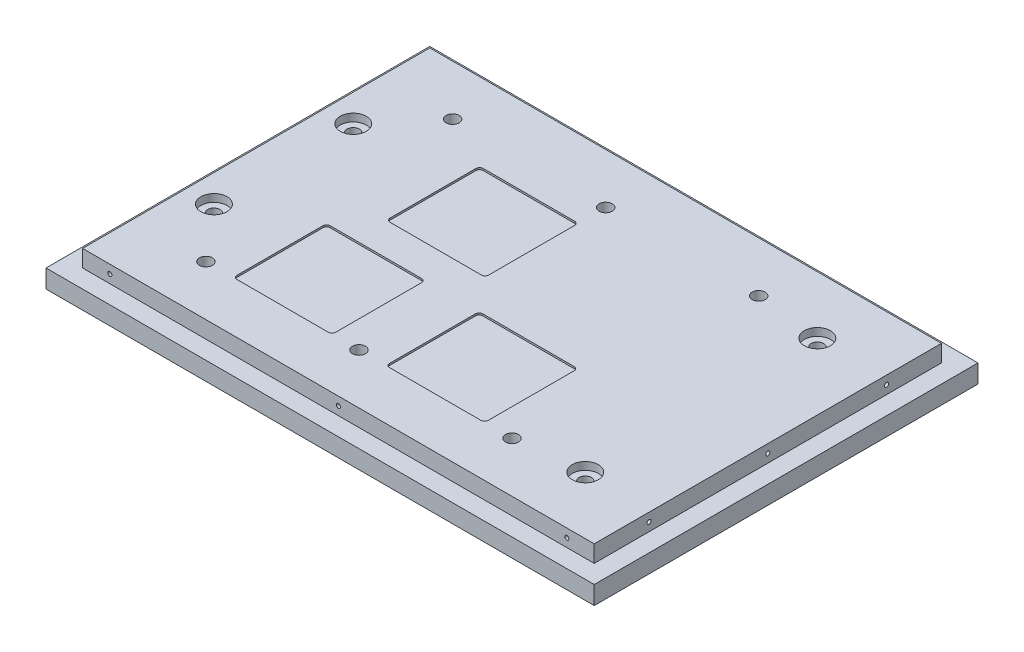
from build123d import *

# Parameters (mm, degrees)
SKETCH1_W                                            = 300
SKETCH1_H                                            = 210
BOSS_EXTRUDE1_DEPTH                                  = 10
SKETCH2_W                                            = 280
SKETCH2_H                                            = 190
BOSS_EXTRUDE2_DEPTH                                  = 9.28
F_1_4_20_CLEARANCE_HOLES_REACH                       = 21.28
SKETCH3_R                                            = 3.57
SKETCH4_R                                            = 7.5
CUT_EXTRUDE2_DEPTH                                   = 10
SKETCH11_W                                           = 54
SKETCH11_H                                           = 51
TEC_DEPTH                                            = 1
FILLET1_R                                            = 2
F_4_40_TAPPED_HOLE1_D                                = 2.2606
F_4_40_TAPPED_HOLE1_DEPTH                            = 13
F_4_40_TAPPED_HOLE1_TIP                              = 0.679152758
F_4_40_TAPPED_HOLE2_D                                = 2.2606
F_4_40_TAPPED_HOLE2_DEPTH                            = 13
F_4_40_TAPPED_HOLE2_TIP                              = 0.679152758
F_4_40_TAPPED_HOLE3_D                                = 2.2606
F_4_40_TAPPED_HOLE3_DEPTH                            = 13
F_4_40_TAPPED_HOLE3_TIP                              = 0.679152758
F_4_40_TAPPED_HOLE4_D                                = 2.2606
F_4_40_TAPPED_HOLE4_DEPTH                            = 13
F_4_40_TAPPED_HOLE4_TIP                              = 0.679152758
CBORE_FOR_1_4_BINDING_HEAD_MACHINE_SCREW_D           = 6.7564
CBORE_FOR_1_4_BINDING_HEAD_MACHINE_SCREW_CBORE_D     = 14.2875
CBORE_FOR_1_4_BINDING_HEAD_MACHINE_SCREW_CBORE_DEPTH = 4.191


with BuildPart() as part:
    # Sketch1 → Boss-Extrude1 (new body)
    with BuildSketch(Plane(origin=(0, 0, 0), x_dir=(1, 0, 0), z_dir=(0, 1, 0))):
        with Locations((-22.864321608, -2.487437186)):
            Rectangle(SKETCH1_W, SKETCH1_H)
    extrude(amount=BOSS_EXTRUDE1_DEPTH)

    # Sketch2 → Boss-Extrude2 (add)
    with BuildSketch(Plane(origin=(0, 10, 0), x_dir=(1, 0, 0), z_dir=(0, 1, 0))):
        with Locations((-22.864321608, -2.487437186)):
            Rectangle(SKETCH2_W, SKETCH2_H)
    extrude(amount=BOSS_EXTRUDE2_DEPTH)

    # Sketch3 → 1/4-20 clearance holes (cut, up to next)
    with BuildSketch(Plane(origin=(0, 19.28, 0), x_dir=(1, 0, 0), z_dir=(0, 1, 0)), mode=Mode.PRIVATE) as f_1_4_20_clearance_holes_sk1:
        with Locations((-122.864321608, 65.012562814)):
            Circle(SKETCH3_R)
    f_1_4_20_clearance_holes_tool1 = extrude(f_1_4_20_clearance_holes_sk1.sketch, amount=-F_1_4_20_CLEARANCE_HOLES_REACH, mode=Mode.PRIVATE) & part.part
    add(f_1_4_20_clearance_holes_tool1.solids().sort_by_distance((-122.864322, 19.28, -65.012563))[0], mode=Mode.SUBTRACT)
    # Sketch3 → 1/4-20 clearance holes (cut, up to next)
    with BuildSketch(Plane(origin=(0, 19.28, 0), x_dir=(1, 0, 0), z_dir=(0, 1, 0)), mode=Mode.PRIVATE) as f_1_4_20_clearance_holes_sk2:
        with Locations((-39.114321608, 65.012562814)):
            Circle(SKETCH3_R)
    f_1_4_20_clearance_holes_tool2 = extrude(f_1_4_20_clearance_holes_sk2.sketch, amount=-F_1_4_20_CLEARANCE_HOLES_REACH, mode=Mode.PRIVATE) & part.part
    add(f_1_4_20_clearance_holes_tool2.solids().sort_by_distance((-39.114322, 19.28, -65.012563))[0], mode=Mode.SUBTRACT)
    # Sketch3 → 1/4-20 clearance holes (cut, up to next)
    with BuildSketch(Plane(origin=(0, 19.28, 0), x_dir=(1, 0, 0), z_dir=(0, 1, 0)), mode=Mode.PRIVATE) as f_1_4_20_clearance_holes_sk3:
        with Locations((44.635678392, 65.012562814)):
            Circle(SKETCH3_R)
    f_1_4_20_clearance_holes_tool3 = extrude(f_1_4_20_clearance_holes_sk3.sketch, amount=-F_1_4_20_CLEARANCE_HOLES_REACH, mode=Mode.PRIVATE) & part.part
    add(f_1_4_20_clearance_holes_tool3.solids().sort_by_distance((44.635678, 19.28, -65.012563))[0], mode=Mode.SUBTRACT)
    # Sketch3 → 1/4-20 clearance holes (cut, up to next)
    with BuildSketch(Plane(origin=(0, 19.28, 0), x_dir=(1, 0, 0), z_dir=(0, 1, 0)), mode=Mode.PRIVATE) as f_1_4_20_clearance_holes_sk4:
        with Locations((44.635678392, -69.987437186)):
            Circle(SKETCH3_R)
    f_1_4_20_clearance_holes_tool4 = extrude(f_1_4_20_clearance_holes_sk4.sketch, amount=-F_1_4_20_CLEARANCE_HOLES_REACH, mode=Mode.PRIVATE) & part.part
    add(f_1_4_20_clearance_holes_tool4.solids().sort_by_distance((44.635678, 19.28, 69.987437))[0], mode=Mode.SUBTRACT)
    # Sketch3 → 1/4-20 clearance holes (cut, up to next)
    with BuildSketch(Plane(origin=(0, 19.28, 0), x_dir=(1, 0, 0), z_dir=(0, 1, 0)), mode=Mode.PRIVATE) as f_1_4_20_clearance_holes_sk5:
        with Locations((-39.114321608, -69.987437186)):
            Circle(SKETCH3_R)
    f_1_4_20_clearance_holes_tool5 = extrude(f_1_4_20_clearance_holes_sk5.sketch, amount=-F_1_4_20_CLEARANCE_HOLES_REACH, mode=Mode.PRIVATE) & part.part
    add(f_1_4_20_clearance_holes_tool5.solids().sort_by_distance((-39.114322, 19.28, 69.987437))[0], mode=Mode.SUBTRACT)
    # Sketch3 → 1/4-20 clearance holes (cut, up to next)
    with BuildSketch(Plane(origin=(0, 19.28, 0), x_dir=(1, 0, 0), z_dir=(0, 1, 0)), mode=Mode.PRIVATE) as f_1_4_20_clearance_holes_sk6:
        with Locations((-122.864321608, -69.987437186)):
            Circle(SKETCH3_R)
    f_1_4_20_clearance_holes_tool6 = extrude(f_1_4_20_clearance_holes_sk6.sketch, amount=-F_1_4_20_CLEARANCE_HOLES_REACH, mode=Mode.PRIVATE) & part.part
    add(f_1_4_20_clearance_holes_tool6.solids().sort_by_distance((-122.864322, 19.28, 69.987437))[0], mode=Mode.SUBTRACT)

    # Sketch4 → Cut-Extrude2 (cut)
    with BuildSketch(Plane.XZ):
        with Locations((-122.864321608, 69.987437186)):
            Circle(SKETCH4_R)
        with Locations((-39.114321608, 69.987437186)):
            Circle(SKETCH4_R)
        with Locations((44.635678392, 69.987437186)):
            Circle(SKETCH4_R)
        with Locations((44.635678392, -65.012562814)):
            Circle(SKETCH4_R)
        with Locations((-39.114321608, -65.012562814)):
            Circle(SKETCH4_R)
        with Locations((-122.864321608, -65.012562814)):
            Circle(SKETCH4_R)
    extrude(amount=-CUT_EXTRUDE2_DEPTH, mode=Mode.SUBTRACT)

    # Sketch11 → TEC (cut)
    with BuildSketch(Plane(origin=(0, 19.28, 0), x_dir=(1, 0, 0), z_dir=(0, 1, 0))):
        with Locations((-66.114321608, 24.512562814)):
            Rectangle(SKETCH11_W, SKETCH11_H)
        with Locations((-80.864321608, -44.487437186)):
            Rectangle(SKETCH11_W, SKETCH11_H)
        with Locations((2.635678392, -44.487437186)):
            Rectangle(SKETCH11_W, SKETCH11_H)
    extrude(amount=-TEC_DEPTH, mode=Mode.SUBTRACT)

    # Fillet1
    fillet1_edges = [part.edges().sort_by_distance(p)[0] for p in [
        (29.635678392, 18.78, 69.987437186),
        (-24.364321608, 18.78, 69.987437186),
        (-24.364321608, 18.78, 18.987437186),
        (29.635678392, 18.78, 18.987437186),
        (-39.114321608, 18.78, -50.012562814),
        (-39.114321608, 18.78, 0.987437186),
        (-93.114321608, 18.78, 0.987437186),
        (-93.114321608, 18.78, -50.012562814),
        (-53.864321608, 18.78, 69.987437186),
        (-107.864321608, 18.78, 69.987437186),
        (-107.864321608, 18.78, 18.987437186),
        (-53.864321608, 18.78, 18.987437186),
    ]]
    fillet(fillet1_edges, radius=FILLET1_R)

    # #4-40 Tapped Hole1
    with Locations(Plane.ZY.offset(162.864321608)):
        with Locations((-62.512562814, 14.64), (2.487437186, 14.64), (67.487437186, 14.64)):
            Hole(F_4_40_TAPPED_HOLE1_D / 2, depth=F_4_40_TAPPED_HOLE1_DEPTH)
            with Locations((0, 0, -(F_4_40_TAPPED_HOLE1_DEPTH + F_4_40_TAPPED_HOLE1_TIP / 2))):  # 118° drill point
                Cone(0, F_4_40_TAPPED_HOLE1_D / 2, F_4_40_TAPPED_HOLE1_TIP, mode=Mode.SUBTRACT)

    # #4-40 Tapped Hole2
    with Locations(Plane.XY.offset(97.487437186)):
        with Locations((-147.864321608, 14.64), (-22.864321608, 14.64), (102.135678392, 14.64)):
            Hole(F_4_40_TAPPED_HOLE2_D / 2, depth=F_4_40_TAPPED_HOLE2_DEPTH)
            with Locations((0, 0, -(F_4_40_TAPPED_HOLE2_DEPTH + F_4_40_TAPPED_HOLE2_TIP / 2))):  # 118° drill point
                Cone(0, F_4_40_TAPPED_HOLE2_D / 2, F_4_40_TAPPED_HOLE2_TIP, mode=Mode.SUBTRACT)

    # #4-40 Tapped Hole3
    with Locations(Plane(origin=(117.135678392, 0, 0), x_dir=(0, 0, -1), z_dir=(1, 0, 0))):
        with Locations((-67.487437186, 14.64), (-2.487437186, 14.64), (62.512562814, 14.64)):
            Hole(F_4_40_TAPPED_HOLE3_D / 2, depth=F_4_40_TAPPED_HOLE3_DEPTH)
            with Locations((0, 0, -(F_4_40_TAPPED_HOLE3_DEPTH + F_4_40_TAPPED_HOLE3_TIP / 2))):  # 118° drill point
                Cone(0, F_4_40_TAPPED_HOLE3_D / 2, F_4_40_TAPPED_HOLE3_TIP, mode=Mode.SUBTRACT)

    # #4-40 Tapped Hole4
    with Locations(Plane(origin=(0, 0, -92.512562814), x_dir=(-1, 0, 0), z_dir=(0, 0, -1))):
        with Locations((-102.135678392, 14.64), (22.864321608, 14.64), (147.864321608, 14.64)):
            Hole(F_4_40_TAPPED_HOLE4_D / 2, depth=F_4_40_TAPPED_HOLE4_DEPTH)
            with Locations((0, 0, -(F_4_40_TAPPED_HOLE4_DEPTH + F_4_40_TAPPED_HOLE4_TIP / 2))):  # 118° drill point
                Cone(0, F_4_40_TAPPED_HOLE4_D / 2, F_4_40_TAPPED_HOLE4_TIP, mode=Mode.SUBTRACT)

    # CBORE for 1/4 Binding Head Machine Screw1 (through all)
    with Locations(Plane(origin=(0, 19.28, 0), x_dir=(1, 0, 0), z_dir=(0, 1, 0))):
        with Locations((80.735678392, 61.012562814), (80.735678392, -65.987437186), (-147.864321608, 35.612562814), (-147.864321608, -40.587437186)):
            CounterBoreHole(CBORE_FOR_1_4_BINDING_HEAD_MACHINE_SCREW_D / 2, CBORE_FOR_1_4_BINDING_HEAD_MACHINE_SCREW_CBORE_D / 2, CBORE_FOR_1_4_BINDING_HEAD_MACHINE_SCREW_CBORE_DEPTH)


solid = part.part
